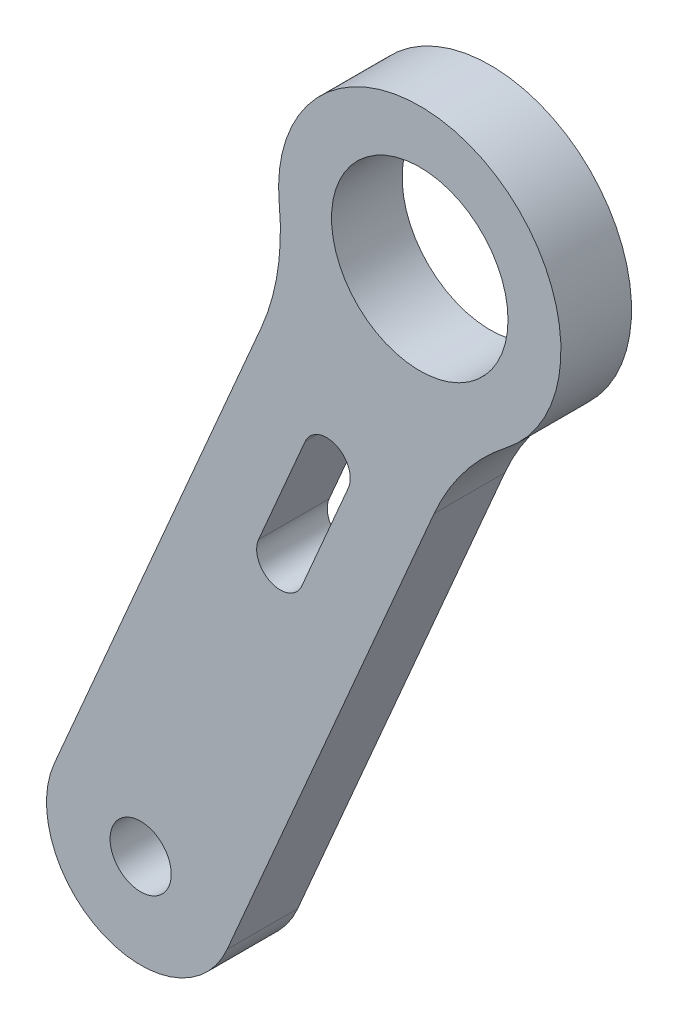
from build123d import *

# Parameters (mm, degrees)
MODEL_R             = 1.3
MODEL_R_2           = 3.74995
BOSS_EXTRUDE1_DEPTH = 3


with BuildPart() as part:
    # Model → Boss-Extrude1 (new body)
    with BuildSketch(Plane.XY):
        with BuildLine():
            Line((59.647938224, 46.456741559), (50.84903604, 26.016099779))
            ThreePointArc((50.84903604, 26.016099779), (52.941556865, 20.760497372), (58.197159265, 22.8530182))
            Line((58.197159265, 22.8530182), (66.996061448, 43.293659979))
            ThreePointArc((66.996061448, 43.293659979), (68.276182261, 45.464386961), (70.05834452, 47.246145252))
            ThreePointArc((70.05834452, 47.246145252), (68.756948833, 57.501076502), (60.413932787, 51.397689825))
            ThreePointArc((60.413932787, 51.397689825), (60.344733109, 48.87856769), (59.647938224, 46.456741559))
        make_face()
        with Locations((54.523097656, 24.434558988)):
            Circle(MODEL_R, mode=Mode.SUBTRACT)
        with Locations((66.384679731, 51.989955386)):
            Circle(MODEL_R_2, mode=Mode.SUBTRACT)
        with BuildLine():
            Line((63.349317004, 42.409481853), (61.372391017, 37.816904838))
            ThreePointArc((61.372391017, 37.816904838), (60.058490416, 37.293774632), (59.535360211, 38.607675233))
            Line((59.535360211, 38.607675233), (61.512286198, 43.200252248))
            ThreePointArc((61.512286198, 43.200252248), (62.826186798, 43.723382454), (63.349317004, 42.409481853))
        make_face(mode=Mode.SUBTRACT)
    extrude(amount=BOSS_EXTRUDE1_DEPTH)


solid = part.part
